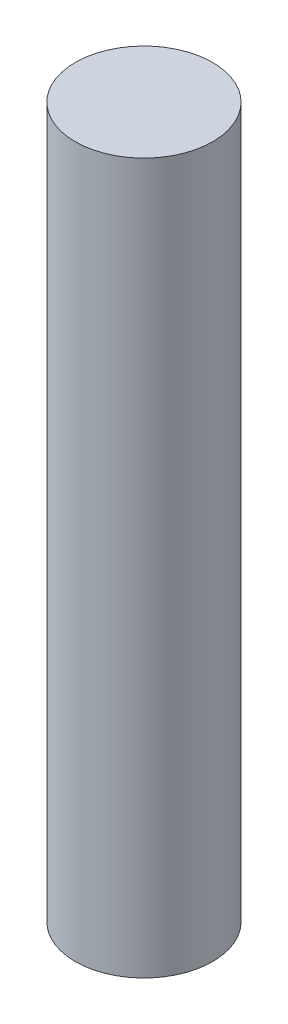
from build123d import *

# Parameters (mm, degrees)
SKETCH1_R           = 4
BOSS_EXTRUDE1_DEPTH = 20.675


with BuildPart() as part:
    # Sketch1 → Boss-Extrude1 (new body, symmetric)
    with BuildSketch(Plane(origin=(0, 0, 0), x_dir=(1, 0, 0), z_dir=(0, 1, 0))):
        Circle(SKETCH1_R)
    extrude(amount=BOSS_EXTRUDE1_DEPTH, both=True)


solid = part.part
